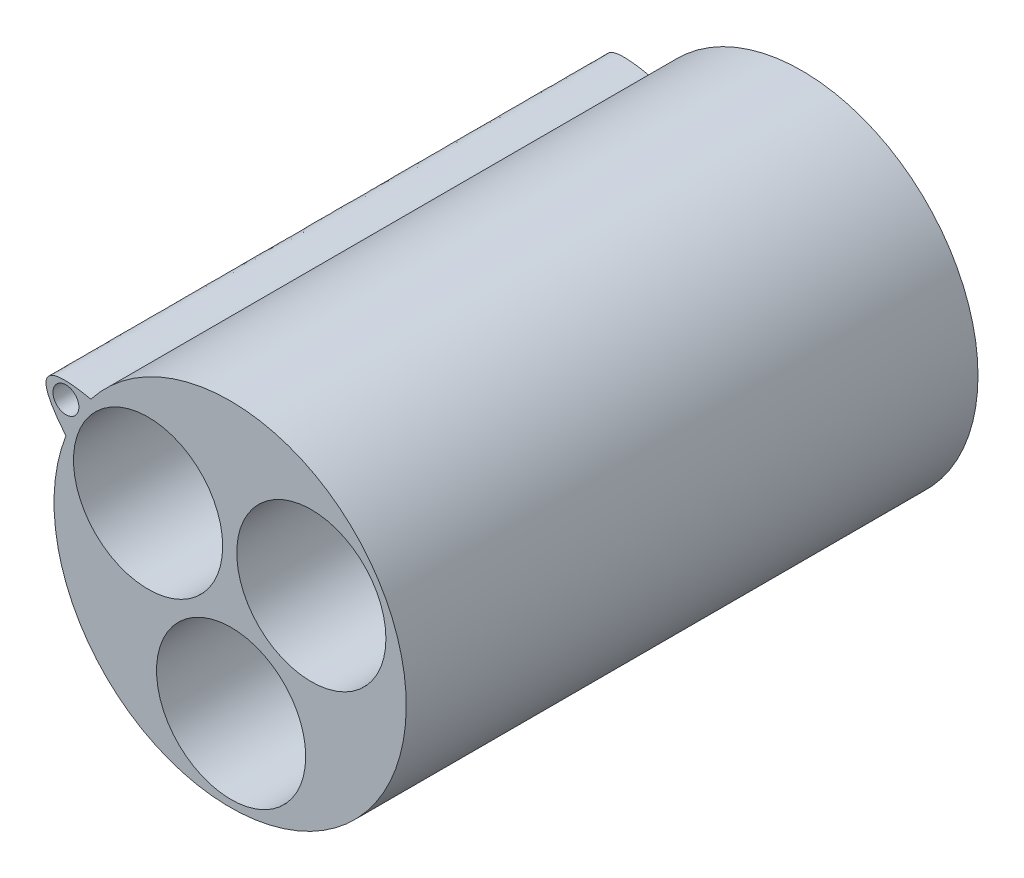
from build123d import *

# Parameters (mm, degrees)
SKETCH1_R           = 21.59
SKETCH1_R_2         = 9.144
BOSS_EXTRUDE1_DEPTH = 70.1
SKETCH2_R           = 1.5875
BOSS_EXTRUDE3_DEPTH = 68.58


with BuildPart() as part:
    # Sketch1 → Boss-Extrude1 (new body)
    with BuildSketch(Plane.XY):
        Circle(SKETCH1_R)
        with Locations((0.118855304, -11.557)):
            Circle(SKETCH1_R_2, mode=Mode.SUBTRACT)
        with Locations((9.955579479, 5.869470694)):
            Circle(SKETCH1_R_2, mode=Mode.SUBTRACT)
        with Locations((-10.060900468, 5.687049391)):
            Circle(SKETCH1_R_2, mode=Mode.SUBTRACT)
    extrude(amount=BOSS_EXTRUDE1_DEPTH)

    # Sketch2 → Boss-Extrude3 (add)
    with BuildSketch(Plane.XY.offset(70.1)):
        with BuildLine():
            ThreePointArc((-20.134392286, 7.793224446), (-18.801139076, 10.613447577), (-17.075379878, 13.212096806))
            add(Edge.make_bspline(
                [(-20.134392286, 7.793224446), (-26.24429958, 15.203378156), (-17.075379878, 13.212096806)],
                knots=[0, 0, 0, 1, 1, 1], degree=2))
        make_face()
        with Locations((-20.134392286, 11.624596806)):
            Circle(SKETCH2_R, mode=Mode.SUBTRACT)
    extrude(amount=-BOSS_EXTRUDE3_DEPTH)


solid = part.part
